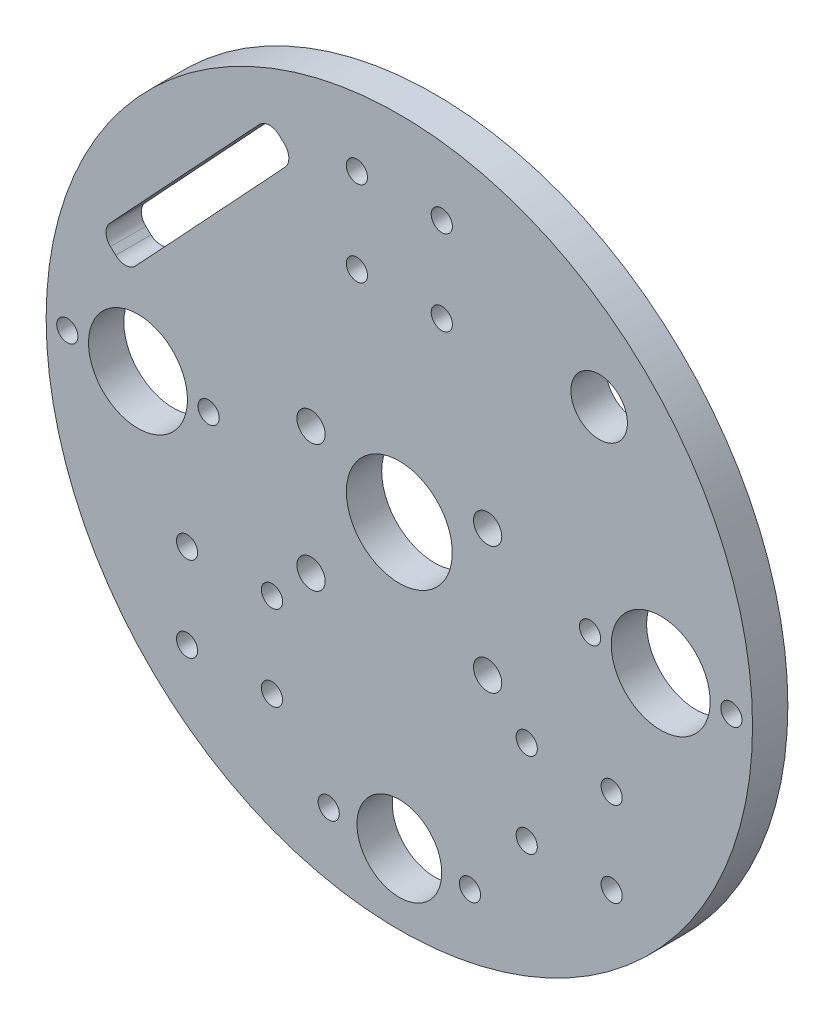
from build123d import *

# Parameters (mm, degrees)
SKETCH1_R                  = 50
BOSS_EXTRUDE1_DEPTH        = 5
F_15_0_15_DIAMETER_HOLE1_D = 15
F_14_0_14_DIAMETER_HOLE1_D = 14
SKETCH9_R                  = 2
CUT_EXTRUDE1_DEPTH         = 10
SKETCH10_R                 = 6
CUT_EXTRUDE2_DEPTH         = 10
SKETCH11_R                 = 1.5
CUT_EXTRUDE3_DEPTH         = 10
SKETCH12_R                 = 1.5
CUT_EXTRUDE4_DEPTH         = 10
SKETCH13_R                 = 1.5
CUT_EXTRUDE5_DEPTH         = 10
SKETCH14_R                 = 4
CUT_EXTRUDE6_DEPTH         = 10
CUT_EXTRUDE7_DEPTH         = 10


with BuildPart() as part:
    # Sketch1 → Boss-Extrude1 (new body)
    with BuildSketch(Plane.XY):
        Circle(SKETCH1_R)
    extrude(amount=BOSS_EXTRUDE1_DEPTH)

    # Ø15.0 (15) Diameter Hole1 (through all)
    with Locations(Plane(origin=(0, 0, 0), x_dir=(-1, 0, 0), z_dir=(0, 0, -1))):
        with Locations((0, 0)):
            Hole(F_15_0_15_DIAMETER_HOLE1_D / 2)

    # Ø14.0 (14) Diameter Hole1 (through all)
    with Locations(Plane(origin=(0, 0, 0), x_dir=(-1, 0, 0), z_dir=(0, 0, -1))):
        with Locations((37, 0), (-37, 0)):
            Hole(F_14_0_14_DIAMETER_HOLE1_D / 2)

    # Sketch9 → Cut-Extrude1 (cut)
    with BuildSketch(Plane.XY.offset(5)):
        with Locations((12.5, 5.5)):
            Circle(SKETCH9_R)
        with Locations((12.5, -12.5)):
            Circle(SKETCH9_R)
        with Locations((-12.5, -12.5)):
            Circle(SKETCH9_R)
        with Locations((-12.5, 5.5)):
            Circle(SKETCH9_R)
    extrude(amount=-CUT_EXTRUDE1_DEPTH, mode=Mode.SUBTRACT)

    # Sketch10 → Cut-Extrude2 (cut)
    with BuildSketch(Plane.XY.offset(5)):
        with Locations((0, -40)):
            Circle(SKETCH10_R)
    extrude(amount=-CUT_EXTRUDE2_DEPTH, mode=Mode.SUBTRACT)

    # Sketch11 → Cut-Extrude3 (cut)
    with BuildSketch(Plane.XY.offset(5)):
        with Locations((30.0520382, -18.03122292)):
            Circle(SKETCH11_R)
        with Locations((30.0520382, -30.0520382)):
            Circle(SKETCH11_R)
        with Locations((18.03122292, -30.0520382)):
            Circle(SKETCH11_R)
        with Locations((18.03122292, -18.03122292)):
            Circle(SKETCH11_R)
    cut_extrude3 = extrude(amount=-CUT_EXTRUDE3_DEPTH, mode=Mode.SUBTRACT)

    # Mirror1: Cut-Extrude3 across plane
    add(cut_extrude3.mirror(Plane(origin=(0, 0, 0), x_dir=(0, 0, 1), z_dir=(1, 0, 0))), mode=Mode.SUBTRACT)

    # Sketch12 → Cut-Extrude4 (cut)
    with BuildSketch(Plane.XY.offset(5)):
        with Locations((6.01040764, 40.01040764)):
            Circle(SKETCH12_R)
        with Locations((6.01040764, 27.98959236)):
            Circle(SKETCH12_R)
        with Locations((-6.01040764, 27.98959236)):
            Circle(SKETCH12_R)
        with Locations((-6.01040764, 40.01040764)):
            Circle(SKETCH12_R)
    extrude(amount=-CUT_EXTRUDE4_DEPTH, mode=Mode.SUBTRACT)

    # Sketch13 → Cut-Extrude5 (cut)
    with BuildSketch(Plane.XY.offset(5)):
        with Locations((-47, 0)):
            Circle(SKETCH13_R)
        with Locations((-27, 0)):
            Circle(SKETCH13_R)
        with Locations((-10, -40)):
            Circle(SKETCH13_R)
        with Locations((10, -40)):
            Circle(SKETCH13_R)
        with Locations((27, 0)):
            Circle(SKETCH13_R)
        with Locations((47, 0)):
            Circle(SKETCH13_R)
    extrude(amount=-CUT_EXTRUDE5_DEPTH, mode=Mode.SUBTRACT)

    # Sketch14 → Cut-Extrude6 (cut)
    with BuildSketch(Plane.XY.offset(5)):
        with Locations((28.284271247, 28.284271247)):
            Circle(SKETCH14_R)
    extrude(amount=-CUT_EXTRUDE6_DEPTH, mode=Mode.SUBTRACT)

    # Sketch15 → Cut-Extrude7 (cut)
    with BuildSketch(Plane.XY.offset(5)):
        with BuildLine():
            Line((-17.012303521, 38.933386687), (-16.280949819, 38.251388327))
            ThreePointArc((-16.280949819, 38.251388327), (-15.646164885, 36.858479918), (-16.182239136, 35.424684204))
            Line((-16.182239136, 35.424684204), (-37.324188298, 12.752719454))
            ThreePointArc((-37.324188298, 12.752719454), (-38.717096708, 12.11793452), (-40.150892422, 12.654008771))
            Line((-40.150892422, 12.654008771), (-40.882246123, 13.336007131))
            ThreePointArc((-40.882246123, 13.336007131), (-41.517031057, 14.728915541), (-40.980956806, 16.162711254))
            Line((-40.980956806, 16.162711254), (-19.839007644, 38.834676004))
            ThreePointArc((-19.839007644, 38.834676004), (-18.446099234, 39.469460938), (-17.012303521, 38.933386687))
        make_face()
    extrude(amount=-CUT_EXTRUDE7_DEPTH, mode=Mode.SUBTRACT)


solid = part.part
